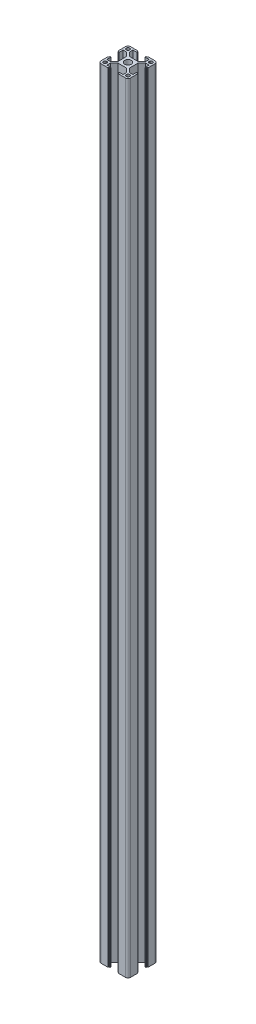
from build123d import *

# Parameters (mm, degrees)
SKETCH_3_R          = 3.4
EXTRUDE_1_DEPTH     = 789
SKETCH_4_R          = 3
CUT_EXTRUDE_1_DEPTH = 86


with BuildPart() as part:
    # 草图3 → 凸台-拉伸1 (new body)
    with BuildSketch(Plane(origin=(0, 0, 0), x_dir=(1, 0, 0), z_dir=(0, 1, 0))):
        with BuildLine():
            Line((-15, -12.5), (-15, -5.4))
            ThreePointArc((-15, -5.4), (-14.941421356, -5.258578644), (-14.8, -5.2))
            Line((-14.8, -5.2), (-14.4, -5.2))
            ThreePointArc((-14.4, -5.2), (-14.258578644, -5.141421356), (-14.2, -5))
            Line((-14.2, -5), (-14.2, -4.3))
            ThreePointArc((-14.2, -4.3), (-14.141421356, -4.158578644), (-14, -4.1))
            Line((-14, -4.1), (-13.2, -4.1))
            Line((-13.2, -4.1), (-13.2, -8.25))
            Line((-13.2, -8.25), (-9.522792206, -8.25))
            Line((-9.522792206, -8.25), (-5.8, -4.527207794))
            Line((-5.8, -4.527207794), (-5.8, 4.527207794))
            Line((-5.8, 4.527207794), (-9.522792206, 8.25))
            Line((-9.522792206, 8.25), (-13.2, 8.25))
            Line((-13.2, 8.25), (-13.2, 4.1))
            Line((-13.2, 4.1), (-14, 4.1))
            ThreePointArc((-14, 4.1), (-14.141421356, 4.158578644), (-14.2, 4.3))
            Line((-14.2, 4.3), (-14.2, 5))
            ThreePointArc((-14.2, 5), (-14.258578644, 5.141421356), (-14.4, 5.2))
            Line((-14.4, 5.2), (-14.8, 5.2))
            ThreePointArc((-14.8, 5.2), (-14.941421356, 5.258578644), (-15, 5.4))
            Line((-15, 5.4), (-15, 12.5))
            ThreePointArc((-15, 12.5), (-14.267766953, 14.267766953), (-12.5, 15))
            Line((-12.5, 15), (-5.4, 15))
            ThreePointArc((-5.4, 15), (-5.258578644, 14.941421356), (-5.2, 14.8))
            Line((-5.2, 14.8), (-5.2, 14.4))
            ThreePointArc((-5.2, 14.4), (-5.141421356, 14.258578644), (-5, 14.2))
            Line((-5, 14.2), (-4.3, 14.2))
            ThreePointArc((-4.3, 14.2), (-4.158578644, 14.141421356), (-4.1, 14))
            Line((-4.1, 14), (-4.1, 13.2))
            Line((-4.1, 13.2), (-8.25, 13.2))
            Line((-8.25, 13.2), (-8.25, 9.522792206))
            Line((-8.25, 9.522792206), (-4.527207794, 5.8))
            Line((-4.527207794, 5.8), (4.527207794, 5.8))
            Line((4.527207794, 5.8), (8.25, 9.522792206))
            Line((8.25, 9.522792206), (8.25, 13.2))
            Line((8.25, 13.2), (4.1, 13.2))
            Line((4.1, 13.2), (4.1, 14))
            ThreePointArc((4.1, 14), (4.158578644, 14.141421356), (4.3, 14.2))
            Line((4.3, 14.2), (5, 14.2))
            ThreePointArc((5, 14.2), (5.141421356, 14.258578644), (5.2, 14.4))
            Line((5.2, 14.4), (5.2, 14.8))
            ThreePointArc((5.2, 14.8), (5.258578644, 14.941421356), (5.4, 15))
            Line((5.4, 15), (12.5, 15))
            ThreePointArc((12.5, 15), (14.267766953, 14.267766953), (15, 12.5))
            Line((15, 12.5), (15, 5.4))
            ThreePointArc((15, 5.4), (14.941421356, 5.258578644), (14.8, 5.2))
            Line((14.8, 5.2), (14.4, 5.2))
            ThreePointArc((14.4, 5.2), (14.258578644, 5.141421356), (14.2, 5))
            Line((14.2, 5), (14.2, 4.3))
            ThreePointArc((14.2, 4.3), (14.141421356, 4.158578644), (14, 4.1))
            Line((14, 4.1), (13.2, 4.1))
            Line((13.2, 4.1), (13.2, 8.25))
            Line((13.2, 8.25), (9.522792206, 8.25))
            Line((9.522792206, 8.25), (5.8, 4.527207794))
            Line((5.8, 4.527207794), (5.8, -4.527207794))
            Line((5.8, -4.527207794), (9.522792206, -8.25))
            Line((9.522792206, -8.25), (13.2, -8.25))
            Line((13.2, -8.25), (13.2, -4.1))
            Line((13.2, -4.1), (14, -4.1))
            ThreePointArc((14, -4.1), (14.141421356, -4.158578644), (14.2, -4.3))
            Line((14.2, -4.3), (14.2, -5))
            ThreePointArc((14.2, -5), (14.258578644, -5.141421356), (14.4, -5.2))
            Line((14.4, -5.2), (14.8, -5.2))
            ThreePointArc((14.8, -5.2), (14.941421356, -5.258578644), (15, -5.4))
            Line((15, -5.4), (15, -12.5))
            ThreePointArc((15, -12.5), (14.267766953, -14.267766953), (12.5, -15))
            Line((12.5, -15), (5.4, -15))
            ThreePointArc((5.4, -15), (5.258578644, -14.941421356), (5.2, -14.8))
            Line((5.2, -14.8), (5.2, -14.4))
            ThreePointArc((5.2, -14.4), (5.141421356, -14.258578644), (5, -14.2))
            Line((5, -14.2), (4.3, -14.2))
            ThreePointArc((4.3, -14.2), (4.158578644, -14.141421356), (4.1, -14))
            Line((4.1, -14), (4.1, -13.2))
            Line((4.1, -13.2), (8.25, -13.2))
            Line((8.25, -13.2), (8.25, -9.522792206))
            Line((8.25, -9.522792206), (4.527207794, -5.8))
            Line((4.527207794, -5.8), (-4.527207794, -5.8))
            Line((-4.527207794, -5.8), (-8.25, -9.522792206))
            Line((-8.25, -9.522792206), (-8.25, -13.2))
            Line((-8.25, -13.2), (-4.1, -13.2))
            Line((-4.1, -13.2), (-4.1, -14))
            ThreePointArc((-4.1, -14), (-4.158578644, -14.141421356), (-4.3, -14.2))
            Line((-4.3, -14.2), (-5, -14.2))
            ThreePointArc((-5, -14.2), (-5.141421356, -14.258578644), (-5.2, -14.4))
            Line((-5.2, -14.4), (-5.2, -14.8))
            ThreePointArc((-5.2, -14.8), (-5.258578644, -14.941421356), (-5.4, -15))
            Line((-5.4, -15), (-12.5, -15))
            ThreePointArc((-12.5, -15), (-14.267766953, -14.267766953), (-15, -12.5))
        make_face()
        Circle(SKETCH_3_R, mode=Mode.SUBTRACT)
        with BuildLine():
            Line((-13.2, -12.2), (-13.2, -11.05))
            ThreePointArc((-13.2, -11.05), (-12.907106781, -10.342893219), (-12.2, -10.05))
            Line((-12.2, -10.05), (-11.05, -10.05))
            ThreePointArc((-11.05, -10.05), (-10.342893219, -10.342893219), (-10.05, -11.05))
            Line((-10.05, -11.05), (-10.05, -12.2))
            ThreePointArc((-10.05, -12.2), (-10.342893219, -12.907106781), (-11.05, -13.2))
            Line((-11.05, -13.2), (-12.2, -13.2))
            ThreePointArc((-12.2, -13.2), (-12.907106781, -12.907106781), (-13.2, -12.2))
        make_face(mode=Mode.SUBTRACT)
        with BuildLine():
            Line((-10.05, 12.2), (-10.05, 11.05))
            ThreePointArc((-10.05, 11.05), (-10.342893219, 10.342893219), (-11.05, 10.05))
            Line((-11.05, 10.05), (-12.2, 10.05))
            ThreePointArc((-12.2, 10.05), (-12.907106781, 10.342893219), (-13.2, 11.05))
            Line((-13.2, 11.05), (-13.2, 12.2))
            ThreePointArc((-13.2, 12.2), (-12.907106781, 12.907106781), (-12.2, 13.2))
            Line((-12.2, 13.2), (-11.05, 13.2))
            ThreePointArc((-11.05, 13.2), (-10.342893219, 12.907106781), (-10.05, 12.2))
        make_face(mode=Mode.SUBTRACT)
        with BuildLine():
            Line((13.2, 12.2), (13.2, 11.05))
            ThreePointArc((13.2, 11.05), (12.907106781, 10.342893219), (12.2, 10.05))
            Line((12.2, 10.05), (11.05, 10.05))
            ThreePointArc((11.05, 10.05), (10.342893219, 10.342893219), (10.05, 11.05))
            Line((10.05, 11.05), (10.05, 12.2))
            ThreePointArc((10.05, 12.2), (10.342893219, 12.907106781), (11.05, 13.2))
            Line((11.05, 13.2), (12.2, 13.2))
            ThreePointArc((12.2, 13.2), (12.907106781, 12.907106781), (13.2, 12.2))
        make_face(mode=Mode.SUBTRACT)
        with BuildLine():
            Line((10.05, -12.2), (10.05, -11.05))
            ThreePointArc((10.05, -11.05), (10.342893219, -10.342893219), (11.05, -10.05))
            Line((11.05, -10.05), (12.2, -10.05))
            ThreePointArc((12.2, -10.05), (12.907106781, -10.342893219), (13.2, -11.05))
            Line((13.2, -11.05), (13.2, -12.2))
            ThreePointArc((13.2, -12.2), (12.907106781, -12.907106781), (12.2, -13.2))
            Line((12.2, -13.2), (11.05, -13.2))
            ThreePointArc((11.05, -13.2), (10.342893219, -12.907106781), (10.05, -12.2))
        make_face(mode=Mode.SUBTRACT)
    extrude(amount=EXTRUDE_1_DEPTH)

    # 草图4 → 切除-拉伸1 (cut)
    with BuildSketch(Plane.XY.offset(5.8)):
        with Locations((0, 609)):
            Circle(SKETCH_4_R)
        with Locations((0, 180)):
            Circle(SKETCH_4_R)
        with Locations((0, 394.5)):
            Circle(SKETCH_4_R)
    extrude(amount=-CUT_EXTRUDE_1_DEPTH, mode=Mode.SUBTRACT)


solid = part.part
